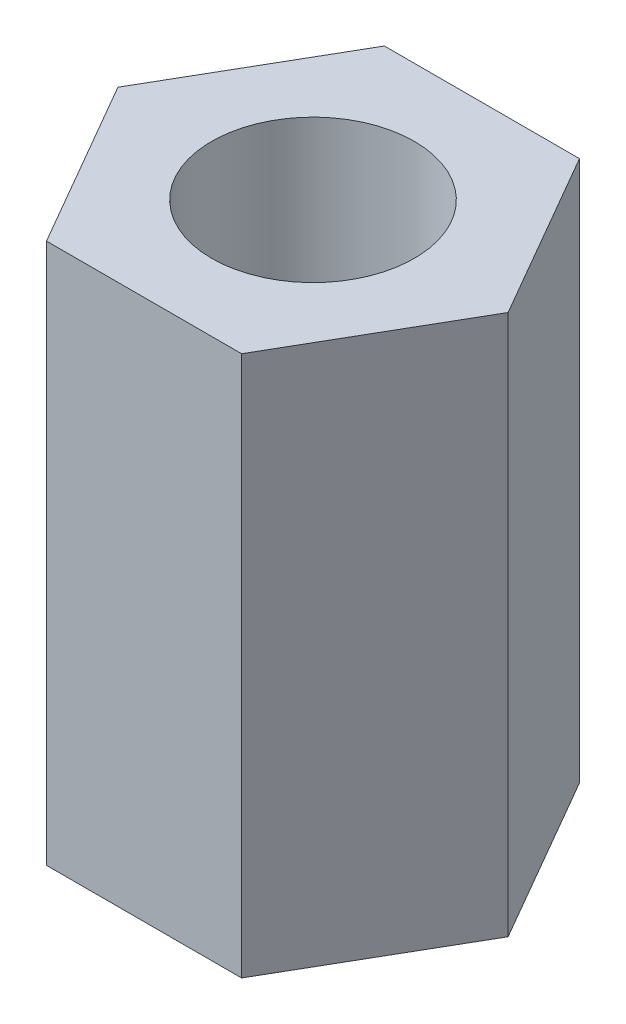
from build123d import *

# Parameters (mm, degrees)
SKETCH1_R           = 1.5
BOSS_EXTRUDE1_DEPTH = 8


with BuildPart() as part:
    # Sketch1 → Boss-Extrude1 (new body)
    with BuildSketch(Plane(origin=(0, 0, 0), x_dir=(1, 0, 0), z_dir=(0, 1, 0))):
        Polygon((-1.443375673, -2.5), (1.443375673, -2.5), (2.886751346, 0), (1.443375673, 2.5), (-1.443375673, 2.5), (-2.886751346, 0), align=None)
        Circle(SKETCH1_R, mode=Mode.SUBTRACT)
    extrude(amount=BOSS_EXTRUDE1_DEPTH)


solid = part.part
